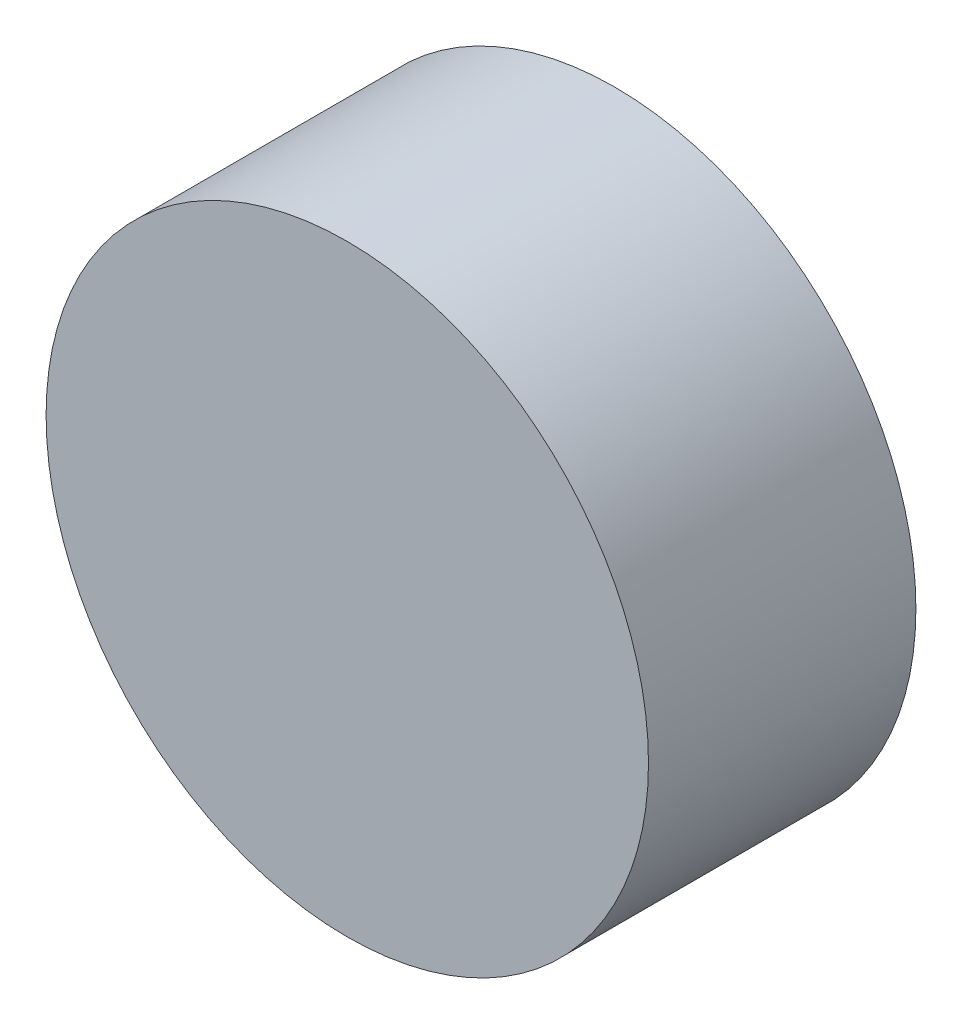
from build123d import *

# Parameters (mm, degrees)
SKETCH1_R           = 12.8397
BOSS_EXTRUDE1_DEPTH = 11.4


with BuildPart() as part:
    # Sketch1 → Boss-Extrude1 (new body)
    with BuildSketch(Plane.XY):
        Circle(SKETCH1_R)
    extrude(amount=BOSS_EXTRUDE1_DEPTH)


solid = part.part
